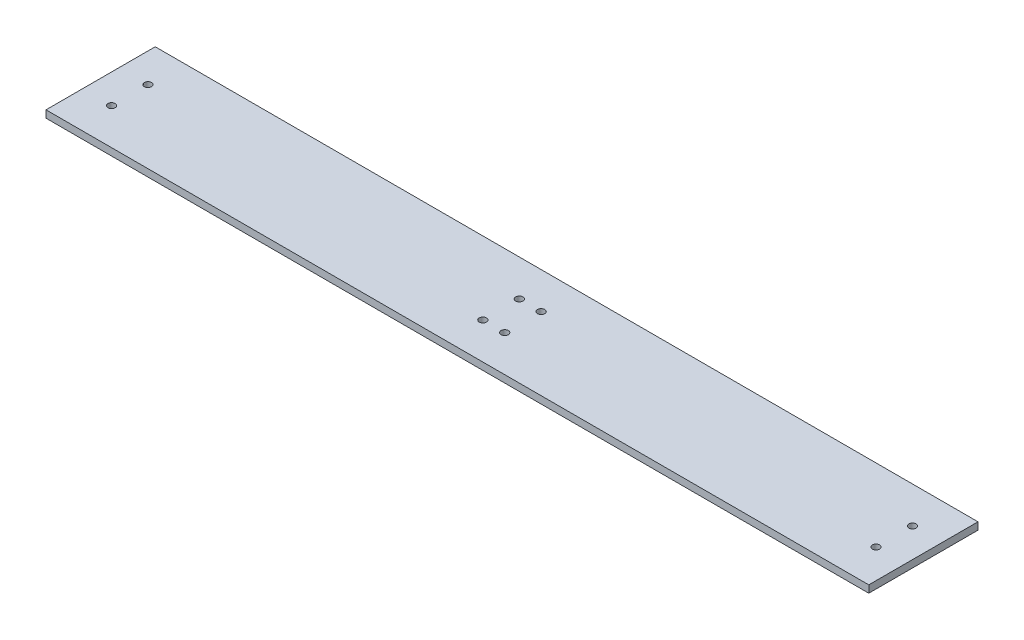
from build123d import *

# Parameters (mm, degrees)
SKETCH_1_W          = 150
SKETCH_1_H          = 10
EXTRUDE_1_DEPTH     = 1130
SKETCH_2_R          = 5
CUT_EXTRUDE_1_DEPTH = 11


with BuildPart() as part:
    # Эскиз1 → Бобышка-Вытянуть1 (new body)
    with BuildSketch(Plane(origin=(0, 0, 0), x_dir=(0, 0, -1), z_dir=(1, 0, 0))):
        with Locations((75, 5)):
            Rectangle(SKETCH_1_W, SKETCH_1_H)
    extrude(amount=EXTRUDE_1_DEPTH)

    # Эскиз2 → Вырез-Вытянуть1 (cut, through all)
    with BuildSketch(Plane(origin=(0, 10, 0), x_dir=(1, 0, 0), z_dir=(0, 1, 0))):
        with Locations((40, 50)):
            Circle(SKETCH_2_R)
        with Locations((550, 50)):
            Circle(SKETCH_2_R)
        with Locations((550, 100)):
            Circle(SKETCH_2_R)
        with Locations((40, 100)):
            Circle(SKETCH_2_R)
        with Locations((1090, 100)):
            Circle(SKETCH_2_R)
        with Locations((580, 100)):
            Circle(SKETCH_2_R)
        with Locations((580, 50)):
            Circle(SKETCH_2_R)
        with Locations((1090, 50)):
            Circle(SKETCH_2_R)
    extrude(amount=-CUT_EXTRUDE_1_DEPTH, mode=Mode.SUBTRACT)


solid = part.part
